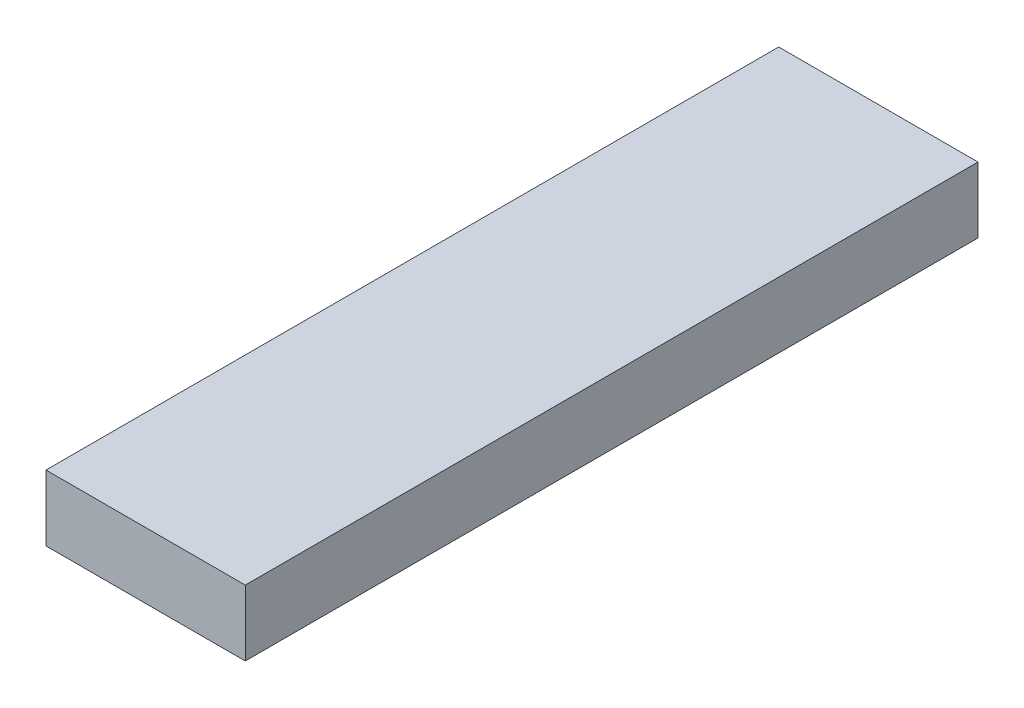
from build123d import *

# Parameters (mm, degrees)
SKETCH1_W           = 25.4
SKETCH1_H           = 93.391876518
BOSS_EXTRUDE1_DEPTH = 8.382


with BuildPart() as part:
    # Sketch1 → Boss-Extrude1 (new body)
    with BuildSketch(Plane(origin=(0, 0, 0), x_dir=(1, 0, 0), z_dir=(0, 1, 0))):
        with Locations((-9.820929351, -2.481119335)):
            Rectangle(SKETCH1_W, SKETCH1_H)
    extrude(amount=BOSS_EXTRUDE1_DEPTH)


solid = part.part
